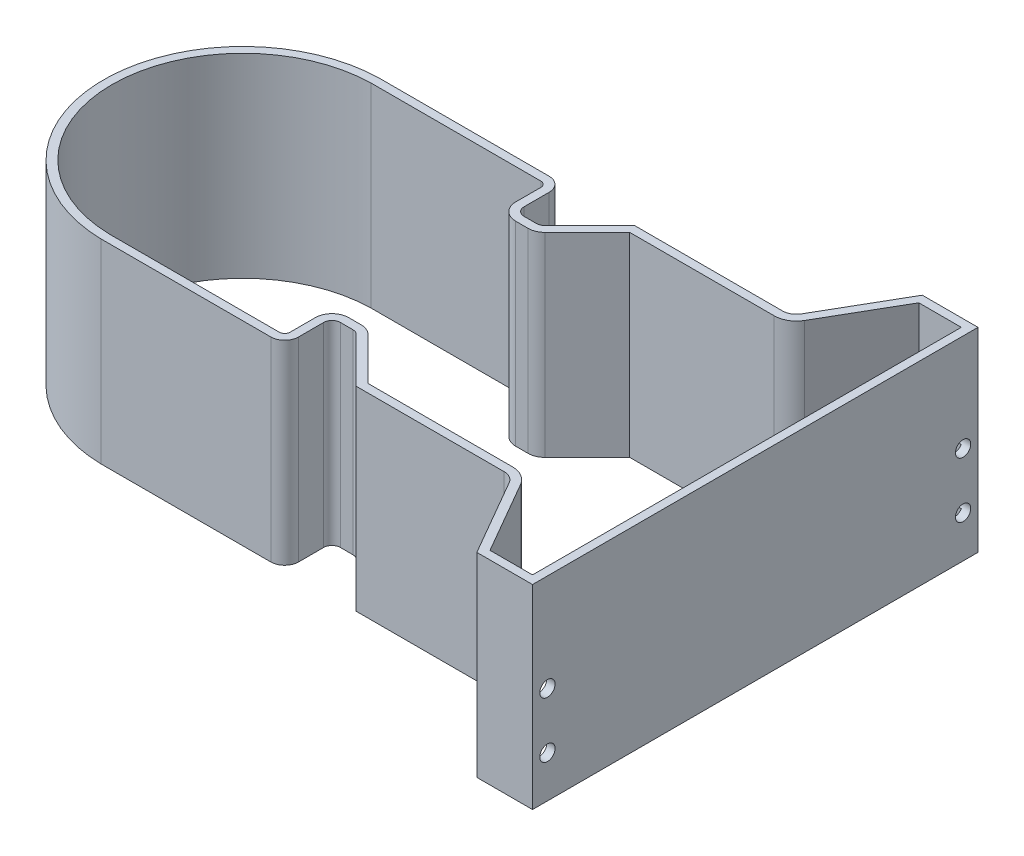
from build123d import *

# Parameters (mm, degrees)
BOSS_EXTRUDE1_DEPTH = 70
CUT_EXTRUDE3_DEPTH  = 70
SKETCH3_R           = 2.75
CUT_EXTRUDE6_DEPTH  = 5


with BuildPart() as part:
    # Sketch1 → Boss-Extrude1 (new body)
    with BuildSketch(Plane(origin=(0, 0, 0), x_dir=(1, 0, 0), z_dir=(0, 1, 0))):
        with BuildLine():
            Line((15.254575611, 35.990242765), (15.254575611, 44.990242765))
            ThreePointArc((15.254575611, 44.990242765), (13.790109517, 48.525776671), (10.254575611, 49.990242765))
            Line((10.254575611, 49.990242765), (-50.745424389, 49.990242765))
            ThreePointArc((-50.745424389, 49.990242765), (-99.757685432, 0), (-50.745424389, -49.990242765))
            Line((-50.745424389, -49.990242765), (10.254575611, -49.990242765))
            ThreePointArc((10.254575611, -49.990242765), (13.790109517, -48.525776671), (15.254575611, -44.990242765))
            Line((15.254575611, -44.990242765), (15.254575611, -35.990242765))
            ThreePointArc((15.254575611, -35.990242765), (16.133255268, -33.868922422), (18.254575611, -32.990242765))
            Line((18.254575611, -32.990242765), (22.711934924, -32.990242765))
            ThreePointArc((22.711934924, -32.990242765), (23.859985221, -33.218604168), (24.833255268, -33.868922422))
            Line((24.833255268, -33.868922422), (40.954575611, -49.990242765))
            Line((40.954575611, -49.990242765), (50.745424389, -49.990242765))
            Line((50.745424389, -49.990242765), (94.067824265, -49.990242765))
            ThreePointArc((94.067824265, -49.990242765), (96.567824265, -50.660115747), (98.397951284, -52.490242765))
            Line((98.397951284, -52.490242765), (114.280717029, -80))
            Line((114.280717029, -80), (134.280717029, -80))
            Line((134.280717029, -80), (134.280717029, 80))
            Line((134.280717029, 80), (114.280717029, 80))
            Line((114.280717029, 80), (98.397951284, 52.490242765))
            ThreePointArc((98.397951284, 52.490242765), (96.567824265, 50.660115747), (94.067824265, 49.990242765))
            Line((94.067824265, 49.990242765), (50.745424389, 49.990242765))
            Line((50.745424389, 49.990242765), (40.954575611, 49.990242765))
            Line((40.954575611, 49.990242765), (24.833255268, 33.868922422))
            ThreePointArc((24.833255268, 33.868922422), (23.859985221, 33.218604168), (22.711934924, 32.990242765))
            Line((22.711934924, 32.990242765), (18.254575611, 32.990242765))
            ThreePointArc((18.254575611, 32.990242765), (16.133255268, 33.868922422), (15.254575611, 35.990242765))
        make_face()
    extrude(amount=BOSS_EXTRUDE1_DEPTH)

    # Sketch5 → Cut-Extrude3 (cut)
    with BuildSketch(Plane(origin=(0, 70, 0), x_dir=(1, 0, 0), z_dir=(0, 1, 0))):
        with BuildLine():
            Line((116.012767836, 77), (100.996027496, 50.990242765))
            ThreePointArc((100.996027496, 50.990242765), (98.067824265, 48.062039535), (94.067824265, 46.990242765))
            Line((94.067824265, 46.990242765), (42.197216298, 46.990242765))
            Line((42.197216298, 46.990242765), (26.954575611, 31.747602078))
            ThreePointArc((26.954575611, 31.747602078), (25.008035518, 30.44696557), (22.711934924, 29.990242765))
            Line((22.711934924, 29.990242765), (18.254575611, 29.990242765))
            ThreePointArc((18.254575611, 29.990242765), (14.011934924, 31.747602078), (12.254575611, 35.990242765))
            Line((12.254575611, 35.990242765), (12.254575611, 44.990242765))
            ThreePointArc((12.254575611, 44.990242765), (11.668789174, 46.404456328), (10.254575611, 46.990242765))
            Line((10.254575611, 46.990242765), (-50.715330899, 46.990242765))
            ThreePointArc((-50.715330899, 46.990242765), (-96.757685432, 0), (-50.715330899, -46.990242765))
            Line((-50.715330899, -46.990242765), (10.254575611, -46.990242765))
            ThreePointArc((10.254575611, -46.990242765), (11.668789174, -46.404456328), (12.254575611, -44.990242765))
            Line((12.254575611, -44.990242765), (12.254575611, -35.990242765))
            ThreePointArc((12.254575611, -35.990242765), (14.011934924, -31.747602078), (18.254575611, -29.990242765))
            Line((18.254575611, -29.990242765), (22.711934924, -29.990242765))
            ThreePointArc((22.711934924, -29.990242765), (25.008035518, -30.44696557), (26.954575611, -31.747602078))
            Line((26.954575611, -31.747602078), (42.197216298, -46.990242765))
            Line((42.197216298, -46.990242765), (94.067824265, -46.990242765))
            ThreePointArc((94.067824265, -46.990242765), (98.067824265, -48.062039535), (100.996027496, -50.990242765))
            Line((100.996027496, -50.990242765), (116.012767836, -77))
            Line((116.012767836, -77), (131.280717029, -77))
            Line((131.280717029, -77), (131.280717029, 77))
            Line((131.280717029, 77), (116.012767836, 77))
        make_face()
    extrude(amount=-CUT_EXTRUDE3_DEPTH, mode=Mode.SUBTRACT)

    # Sketch3 → Cut-Extrude6 (cut)
    with BuildSketch(Plane(origin=(134.280717029, 0, 0), x_dir=(0, 0, -1), z_dir=(1, 0, 0))):
        with Locations((-74.64699859, 15)):
            Circle(SKETCH3_R)
        with Locations((-74.64699859, 35)):
            Circle(SKETCH3_R)
        with Locations((74.64699859, 35)):
            Circle(SKETCH3_R)
        with Locations((74.64699859, 15)):
            Circle(SKETCH3_R)
    extrude(amount=-CUT_EXTRUDE6_DEPTH, mode=Mode.SUBTRACT)


solid = part.part
